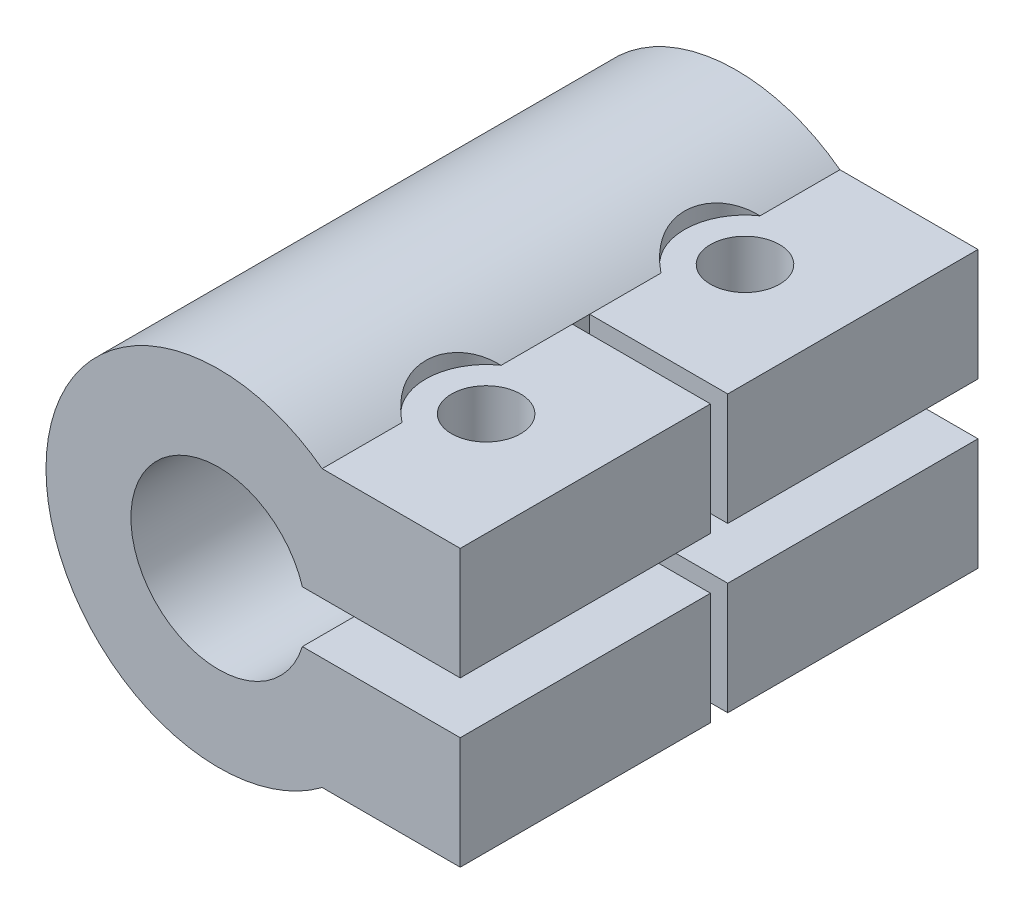
from build123d import *

# Parameters (mm, degrees)
BOSS_EXTRUDE1_DEPTH     = 30
SKETCH3_R               = 2
CUT_EXTRUDE2_DEPTH      = 19.00000001
SKETCH8_R               = 3.5
CUT_EXTRUDE5_DEPTH      = 10
SKETCH9_W               = 8.000001136
SKETCH9_H               = 1
CUT_EXTRUDE6_DEPTH      = 2.999999513
CUT_EXTRUDE6_DEPTH_BACK = 19.00000011
CUT_EXTRUDE7_START      = -3
CUT_EXTRUDE7_DEPTH      = 5.999999514
SKETCH12_R              = 5.08
CUT_EXTRUDE8_DEPTH      = 15


with BuildPart() as part:
    # Sketch1 → Boss-Extrude1 (new body)
    with BuildSketch(Plane.XY):
        with BuildLine():
            Line((7.999999523, 12.236067772), (7.999999523, 7.763931751))
            ThreePointArc((7.999999523, 7.763931751), (10.474207269, 7.037715521), (12.598076062, 8.499999806))
            Line((12.598076062, 8.499999806), (23.999999754, 8.499999806))
            Line((23.999999754, 8.499999806), (23.999999754, 1.999999464))
            Line((23.999999754, 1.999999464), (15.9999988, 1.999999464))
            ThreePointArc((15.9999988, 1.999999464), (-3.4e-08, 9.99999976), (15.999998799, 18.00000006))
            Line((15.999998799, 18.00000006), (23.999999935, 18.00000006))
            Line((23.999999935, 18.00000006), (23.999999935, 11.500000167))
            Line((23.999999935, 11.500000167), (12.598075802, 11.500000167))
            ThreePointArc((12.598075802, 11.500000167), (10.474207012, 12.962284044), (7.999999523, 12.236067772))
        make_face()
    extrude(amount=BOSS_EXTRUDE1_DEPTH)

    # Sketch3 → Cut-Extrude2 (cut, through all)
    with BuildSketch(Plane(origin=(0, 18.00000006, 0), x_dir=(1, 0, 0), z_dir=(0, 1, 0))):
        with Locations((17.999999935, -22.5)):
            Circle(SKETCH3_R)
    cut_extrude2 = extrude(amount=-CUT_EXTRUDE2_DEPTH, mode=Mode.SUBTRACT)

    # Sketch8 → Cut-Extrude5 (cut)
    with BuildSketch(Plane(origin=(0, 18.00000006, 0), x_dir=(1, 0, 0), z_dir=(0, 1, 0))):
        with Locations((17.999999935, -22.5)):
            Circle(SKETCH8_R)
    cut_extrude5 = extrude(amount=CUT_EXTRUDE5_DEPTH, mode=Mode.SUBTRACT)

    # Sketch9 → Cut-Extrude6 (cut, two sides)
    with BuildSketch(Plane(origin=(0, 18.00000006, 0), x_dir=(1, 0, 0), z_dir=(0, 1, 0))) as cut_extrude6_sk:
        with Locations((19.999999367, -15)):
            Rectangle(SKETCH9_W, SKETCH9_H)
    extrude(amount=CUT_EXTRUDE6_DEPTH, mode=Mode.SUBTRACT)
    extrude(cut_extrude6_sk.sketch, amount=-CUT_EXTRUDE6_DEPTH_BACK, mode=Mode.SUBTRACT)

    # Sketch10 → Cut-Extrude7 (cut)
    with BuildSketch(Plane.XZ.offset(-1.999999464).offset(CUT_EXTRUDE7_START)):
        Polygon((15.067996564, 20.882381514), (17.934896952, 19.152001354), (20.866900323, 20.76961984), (20.932003306, 24.117618486), (18.065102919, 25.847998646), (15.133099548, 24.23038016), align=None)
    cut_extrude7 = extrude(amount=CUT_EXTRUDE7_DEPTH, mode=Mode.SUBTRACT)

    # Mirror1: Cut-Extrude7 across plane
    add(cut_extrude7.mirror(Plane.XY.offset(15)), mode=Mode.SUBTRACT)

    # Mirror2: Cut-Extrude2, Cut-Extrude5 across plane
    add(cut_extrude2.mirror(Plane.XY.offset(15)), mode=Mode.SUBTRACT)
    add(cut_extrude5.mirror(Plane.XY.offset(15)), mode=Mode.SUBTRACT)

    # Sketch12 → Cut-Extrude8 (cut)
    with BuildSketch(Plane.XY.offset(30)):
        with Locations((9.999999677, 9.999999762)):
            Circle(SKETCH12_R)
    extrude(amount=-CUT_EXTRUDE8_DEPTH, mode=Mode.SUBTRACT)


solid = part.part
